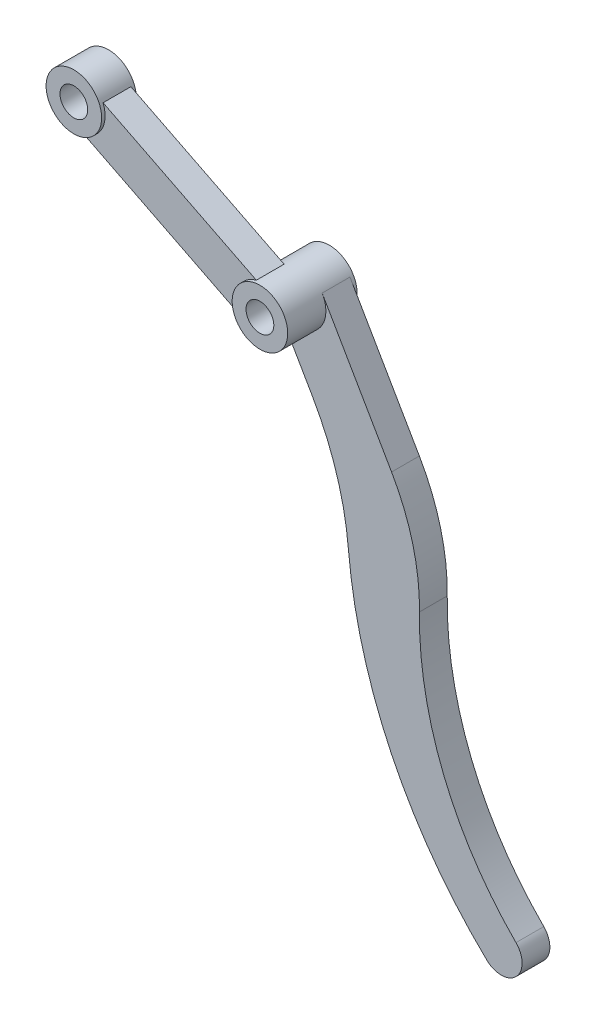
from build123d import *

# Parameters (mm, degrees)
SKETCH_1_R        = 8
SKETCH_1_R_2      = 4
EXTRUDE_1_DEPTH   = 10
EXTRUDE_1_2_DEPTH = 10
EXTRUDE_START     = 1
EXTRUDE_2_DEPTH   = 8
EXTRUDE_START_2   = -1
EXTRUDE_3_DEPTH   = 8
SKETCH_5_R        = 8
SKETCH_5_R_2      = 4
EXTRUDE_4_DEPTH   = 10


with BuildPart() as part:
    # 草图1 → 凸台-拉伸1 (new body)
    with BuildSketch(Plane.XY):
        Circle(SKETCH_1_R)
        Circle(SKETCH_1_R_2, mode=Mode.SUBTRACT)
    extrude(amount=EXTRUDE_1_DEPTH)



with BuildPart() as body_2:
    # 草图1 → Extrude 1 2 (new body)
    with BuildSketch(Plane.XY):
        with Locations((-53.605968084, 26.951812291)):
            Circle(SKETCH_1_R)
        with Locations((-53.605968084, 26.951812291)):
            Circle(SKETCH_1_R_2, mode=Mode.SUBTRACT)
    extrude(amount=EXTRUDE_1_2_DEPTH)


with BuildPart() as part_1:
    add(part.part)

    add(body_2.part)  # 凸台-拉伸2 merges body 2
    # 草图3 → 凸台-拉伸2 (add)
    with BuildSketch(Plane.XY.offset(EXTRUDE_START)):
        with BuildLine():
            Line((-51.573547302, 19.214289059), (-7.42278324, -2.983670385))
            ThreePointArc((-7.42278324, -2.983670385), (-7.147462411, 3.593574972), (-2.032420782, 7.737523232))
            Line((-2.032420782, 7.737523232), (-46.183184844, 29.935482676))
            ThreePointArc((-46.183184844, 29.935482676), (-46.458505673, 23.358237319), (-51.573547302, 19.214289059))
        make_face()
    extrude(amount=EXTRUDE_2_DEPTH)



with BuildPart() as body_2_2:
    # 草图4 → 凸台-拉伸3 (new body)
    with BuildSketch(Plane.XY.offset(EXTRUDE_START_2)):
        with BuildLine():
            Line((6.92820323, 4), (26.92820323, -30.641016151))
            ThreePointArc((26.92820323, -30.641016151), (33.036798625, -45.545943872), (34.959960983, -61.538856509))
            ThreePointArc((34.959960983, -61.538856509), (41.911210079, -98.657642521), (62.774179905, -130.135581289))
            ThreePointArc((62.774179905, -130.135581289), (62.827441336, -138.566924041), (54.397444356, -138.726699833))
            ThreePointArc((54.397444356, -138.726699833), (26.885397662, -101.001387411), (14.477282647, -55.988604867))
            ThreePointArc((14.477282647, -55.988604867), (11.073298234, -38.952300047), (4.07179677, -23.052558883))
            Line((4.07179677, -23.052558883), (-6.92820323, -4))
            ThreePointArc((-6.92820323, -4), (4, -6.92820323), (6.92820323, 4))
        make_face()
    extrude(amount=-EXTRUDE_3_DEPTH)


with BuildPart() as part_2:
    add(part_1.part)

    add(body_2_2.part)  # 凸台-拉伸4 merges body 2 2
    # 草图5 → 凸台-拉伸4 (add)
    with BuildSketch(Plane.XY):
        Circle(SKETCH_5_R)
        Circle(SKETCH_5_R_2, mode=Mode.SUBTRACT)
    extrude(amount=-EXTRUDE_4_DEPTH)


solid = part_2.part
